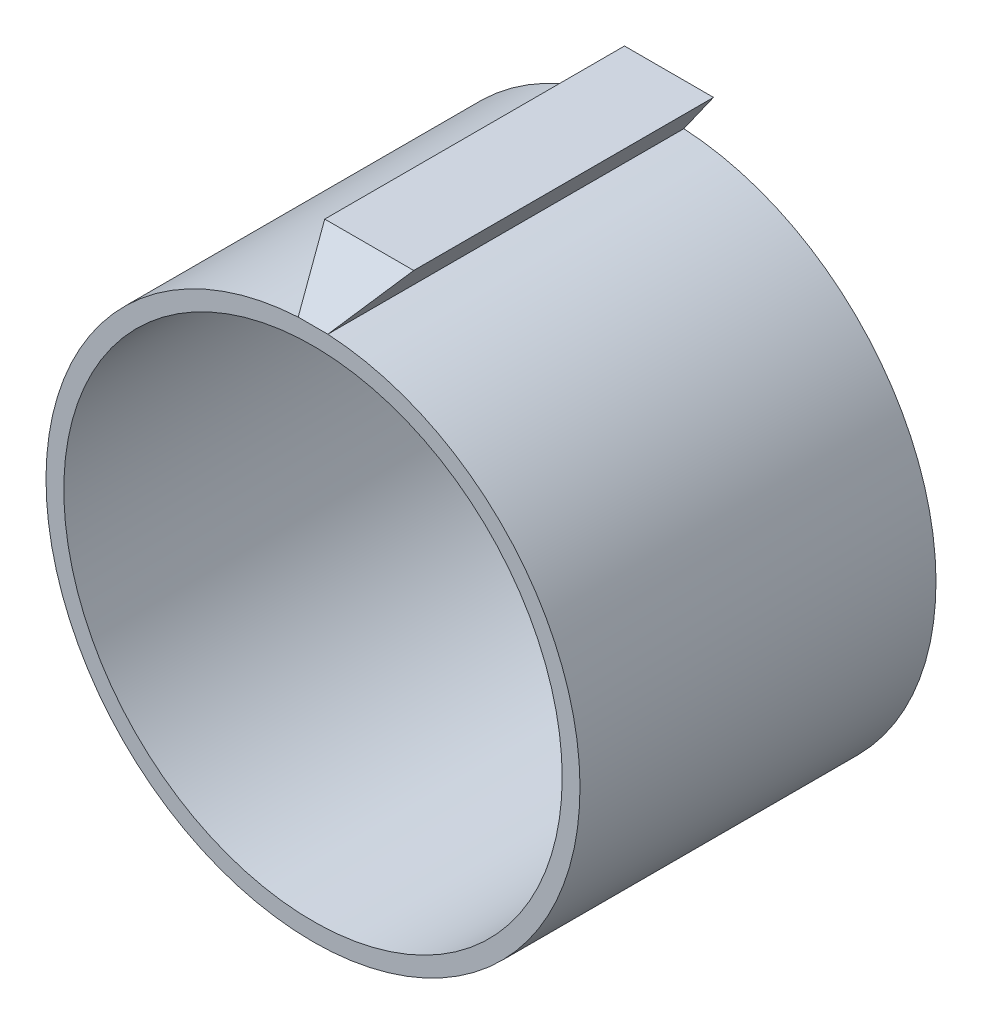
from build123d import *

# Parameters (mm, degrees)
SKETCH1_R                      = 42
BOSS_EXTRUDE1_DEPTH            = 60
CUT_EXTRUDE1_REACH             = 47
CUT_EXTRUDE1_DIRECTION_2_REACH = 47


with BuildPart() as part:
    # Sketch1 → Boss-Extrude1 (new body)
    with BuildSketch(Plane.XY):
        with BuildLine():
            ThreePointArc((2.5, 44.930501889), (15.285447634, 42.324403016), (26.785714286, 36.159722209))
            ThreePointArc((26.785714286, 36.159722209), (-12.910485027, -43.108228639), (-2.5, 44.930501889))
            Line((-2.5, 44.930501889), (-7.5, 52))
            Line((-7.5, 52), (7.5, 52))
            Line((7.5, 52), (2.5, 44.930501889))
        make_face()
        Circle(SKETCH1_R, mode=Mode.SUBTRACT)
    extrude(amount=BOSS_EXTRUDE1_DEPTH)

    # Cut-Extrude1: up to this face of the body (flat: up to its plane)
    cut_extrude1_end = Plane(part.part.faces().sort_by_distance((5, 48.465250945, 30))[0])
    # Sketch2 → Cut-Extrude1 (cut, up to the picked face)
    with BuildSketch(Plane(origin=(0, 0, 0), x_dir=(0, 0, -1), z_dir=(1, 0, 0)), mode=Mode.PRIVATE) as cut_extrude1_sk1:
        Polygon((-60, 44.930501889), (-50.525141204, 52), (-60, 52), align=None)
    cut_extrude1_tool1 = split(extrude(cut_extrude1_sk1.sketch, amount=CUT_EXTRUDE1_REACH, mode=Mode.PRIVATE), bisect_by=cut_extrude1_end, keep=Keep.BOTH, mode=Mode.PRIVATE)
    add(cut_extrude1_tool1.solids().sort_by_distance((0, 49.643501, 56.841714))[0], mode=Mode.SUBTRACT)

    # Cut-Extrude1 direction 2: up to this face of the body (flat: up to its plane)
    cut_extrude1_direction_2_end = Plane(part.part.faces().sort_by_distance((-5, 48.465250945, 30))[0])
    # Sketch2 → Cut-Extrude1 direction 2 (cut, up to the picked face)
    with BuildSketch(Plane(origin=(0, 0, 0), x_dir=(0, 0, -1), z_dir=(1, 0, 0)), mode=Mode.PRIVATE) as cut_extrude1_direction_2_sk1:
        Polygon((-60, 44.930501889), (-50.525141204, 52), (-60, 52), align=None)
    cut_extrude1_direction_2_tool1 = split(extrude(cut_extrude1_direction_2_sk1.sketch, amount=-CUT_EXTRUDE1_DIRECTION_2_REACH, mode=Mode.PRIVATE), bisect_by=cut_extrude1_direction_2_end, keep=Keep.BOTH, mode=Mode.PRIVATE)
    add(cut_extrude1_direction_2_tool1.solids().sort_by_distance((0, 49.643501, 56.841714))[0], mode=Mode.SUBTRACT)


solid = part.part
